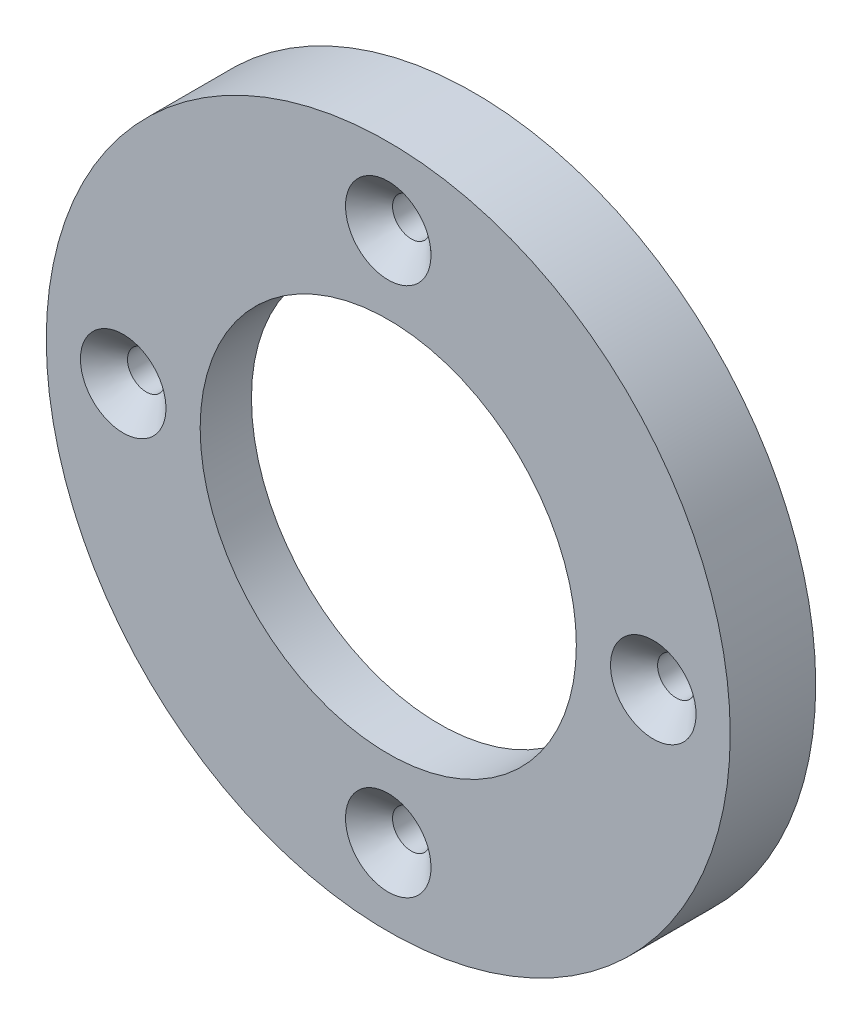
from build123d import *

# Parameters (mm, degrees)
EXTRUDE_1_DEPTH          = 3
SKETCH_2_R               = 11
CUT_EXTRUDE_1_DEPTH      = 4
SKETCH_5_R               = 20
SKETCH_5_R_2             = 18
EXTRUDE_2_DEPTH          = 5
PATTERN_CIRCULAR_1_COUNT = 4
CHAMFER_1_SIZE           = 0.5


with BuildPart() as part:
    # Эскиз1 → Бобышка-Вытянуть1 (new body)
    with BuildSketch(Plane.XY):
        with BuildLine():
            ThreePointArc((-17.685483871, -3.350173167), (-12.727922061, -12.727922061), (-3.350173167, -17.685483871))
            ThreePointArc((-3.350173167, -17.685483871), (10.136595409, -14.874455738), (17.685483871, -3.350173167))
            ThreePointArc((17.685483871, -3.350173167), (12.727922061, 12.727922061), (-3.350173167, 17.685483871))
            ThreePointArc((-3.350173167, 17.685483871), (-14.874455738, 10.136595409), (-17.685483871, -3.350173167))
        make_face()
    extrude(amount=EXTRUDE_1_DEPTH)

    # Эскиз2 → Вырез-Вытянуть1 (cut, through all)
    with BuildSketch(Plane.XY.offset(3)):
        Circle(SKETCH_2_R)
    extrude(amount=-CUT_EXTRUDE_1_DEPTH, mode=Mode.SUBTRACT)

    # Эскиз5 → Бобышка-Вытянуть2 (add)
    with BuildSketch(Plane.XY.offset(3)):
        Circle(SKETCH_5_R)
        Circle(SKETCH_5_R_2, mode=Mode.SUBTRACT)
    extrude(amount=-EXTRUDE_2_DEPTH)

    # Эскиз6 → Вырез-Повернуть1 (revolve, cut)
    with BuildSketch(Plane(origin=(0, 0, 0), x_dir=(1, 0, 0), z_dir=(0, 1, 0))):
        Polygon((-16.6, -1.648035715), (-18, -3), (-15.5, -3), (-15.5, -1.648035715), (-15.5, 2), (-16.6, 2), align=None)
    cut_revolve_1 = revolve(axis=Axis((-15.5, 0, -24.0808518), (0, 0, 1)), mode=Mode.SUBTRACT)

    # Круговой массив1: Вырез-Повернуть1 ×4 about axis
    pattern_circular_1_axis = Axis((0, 0, 0), (0, 0, 1))
    for i in range(1, PATTERN_CIRCULAR_1_COUNT):
        add(cut_revolve_1.rotate(pattern_circular_1_axis, i * 360 / PATTERN_CIRCULAR_1_COUNT), mode=Mode.SUBTRACT)

    # Фаска1
    chamfer_1_edges = [part.edges().sort_by_distance(p)[0] for p in [
        (-18, 0, -2),
    ]]
    chamfer(chamfer_1_edges, length=CHAMFER_1_SIZE)


solid = part.part
